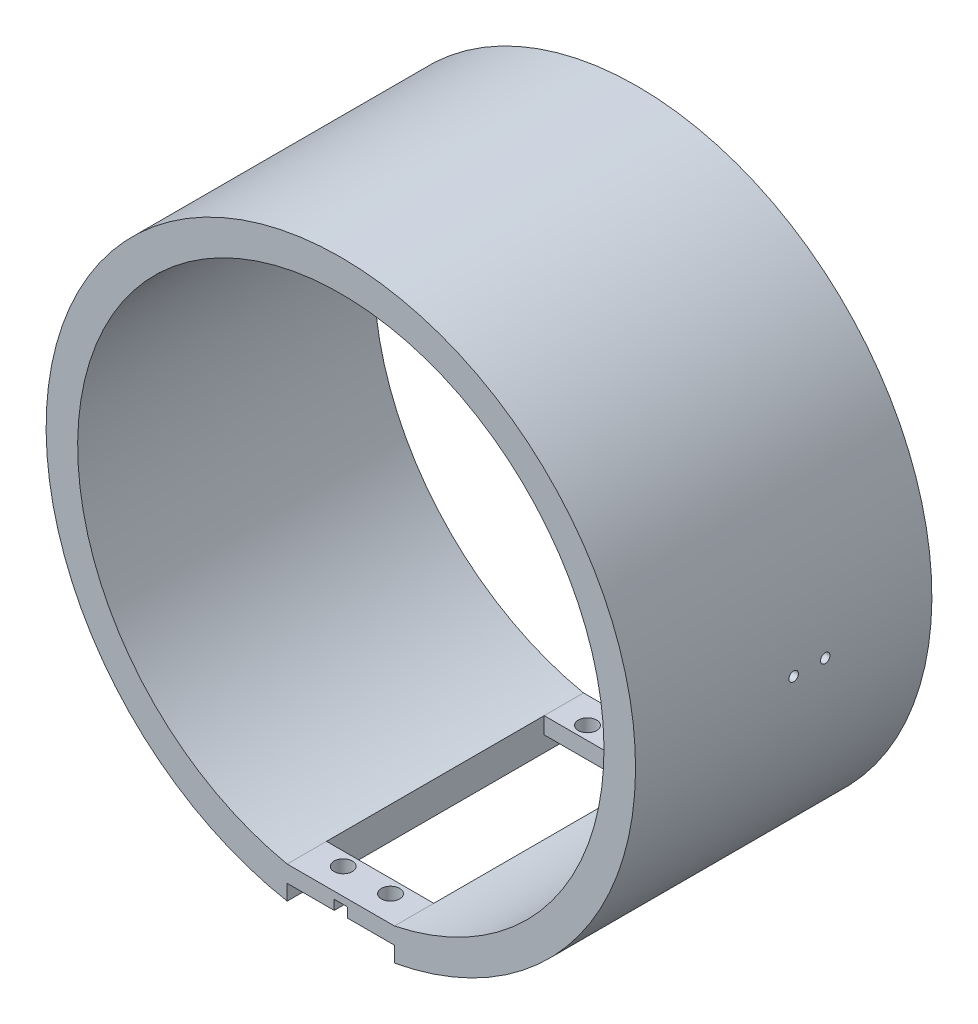
from build123d import *

# Parameters (mm, degrees)
SKETCH1_R                 = 93.40293561
SKETCH1_R_2               = 83.40293561
BOSS_EXTRUDE1_DEPTH       = 93.92
BOSS_EXTRUDE3_DEPTH       = 93.92
CUT_EXTRUDE1_REACH        = 231.001
SKETCH2_W                 = 34
SKETCH2_H                 = 69
CUT_EXTRUDE2_START        = -6.472936
SKETCH3_W                 = 34
SKETCH3_H                 = 12.46
CUT_EXTRUDE2_DEPTH        = 6.472936
M5_CLEARANCE_HOLE1_D      = 5.8
M5_CLEARANCE_HOLE1_DEPTH  = 170.33393561
M5_CLEARANCE_HOLE1_TIP    = 1.742495795
SKETCH8_W                 = 4.19
SKETCH8_H                 = 3.07
CUT_EXTRUDE3_DEPTH        = 12.46
M6_CLEARANCE_HOLE1_REACH  = 219.335
M6_CLEARANCE_HOLE1_BORE_R = 1.5


with BuildPart() as part:
    # Sketch1 → Boss-Extrude1 (new body)
    with BuildSketch(Plane.XY):
        Circle(SKETCH1_R)
        Circle(SKETCH1_R_2, mode=Mode.SUBTRACT)
    extrude(amount=-BOSS_EXTRUDE1_DEPTH)

    # Sketch7 → Boss-Extrude3 (add)
    with BuildSketch(Plane.XY):
        with BuildLine():
            Line((-17, -81.652003456), (17, -81.652003456))
            ThreePointArc((17, -81.652003456), (0, -83.40293561), (-17, -81.652003456))
        make_face()
    extrude(amount=-BOSS_EXTRUDE3_DEPTH)

    # Sketch2 → Cut-Extrude1 (cut, up to next)
    with BuildSketch(Plane(origin=(0, -93.40293561, 0), x_dir=(-1, 0, 0), z_dir=(0, -1, 0)), mode=Mode.PRIVATE) as cut_extrude1_sk1:
        with Locations((0, 46.96)):
            Rectangle(SKETCH2_W, SKETCH2_H)
    cut_extrude1_tool1 = extrude(cut_extrude1_sk1.sketch, amount=-CUT_EXTRUDE1_REACH, mode=Mode.PRIVATE) & part.part
    add(cut_extrude1_tool1.solids().sort_by_distance((0, -93.402936, -46.96))[0], mode=Mode.SUBTRACT)

    # Sketch3 → Cut-Extrude2 (cut)
    with BuildSketch(Plane(origin=(0, -93.40293561, 0), x_dir=(-1, 0, 0), z_dir=(0, -1, 0)).offset(CUT_EXTRUDE2_START)):
        with Locations((0, 87.69)):
            Rectangle(SKETCH3_W, SKETCH3_H)
        with Locations((0, 6.23)):
            Rectangle(SKETCH3_W, SKETCH3_H)
    extrude(amount=CUT_EXTRUDE2_DEPTH, mode=Mode.SUBTRACT)

    # M5 Clearance Hole1
    with Locations(Plane(origin=(-7.5, -86.93, -8.25), x_dir=(0, 0, -1), z_dir=(0, -1, 0))):
        with Locations((0, 0), (0, 15), (77.42, 0), (77.42, 15)):
            Hole(M5_CLEARANCE_HOLE1_D / 2, depth=M5_CLEARANCE_HOLE1_DEPTH)
            with Locations((0, 0, -(M5_CLEARANCE_HOLE1_DEPTH + M5_CLEARANCE_HOLE1_TIP / 2))):  # 118° drill point
                Cone(0, M5_CLEARANCE_HOLE1_D / 2, M5_CLEARANCE_HOLE1_TIP, mode=Mode.SUBTRACT)

    # Sketch8 → Cut-Extrude3 (cut)
    with BuildSketch(Plane.XY):
        with Locations((0, -85.395)):
            Rectangle(SKETCH8_W, SKETCH8_H)
    extrude(amount=-CUT_EXTRUDE3_DEPTH, mode=Mode.SUBTRACT)

    # M6 Clearance Hole1 bore (on position points) → M6 Clearance Hole1 (cut, up to next)
    with BuildSketch(Plane(origin=(93.40293561, 0, -60.116902822), x_dir=(0, 0, 1), z_dir=(1, 0, 0)), mode=Mode.PRIVATE) as m6_clearance_hole1_sk1:
        Circle(M6_CLEARANCE_HOLE1_BORE_R)
    m6_clearance_hole1_tool1 = extrude(m6_clearance_hole1_sk1.sketch, amount=-M6_CLEARANCE_HOLE1_REACH, mode=Mode.PRIVATE) & part.part
    # M6 Clearance Hole1 bore (on position points) → M6 Clearance Hole1 (cut, up to next)
    with BuildSketch(Plane(origin=(93.40293561, 0, -60.116902822), x_dir=(0, 0, 1), z_dir=(1, 0, 0)), mode=Mode.PRIVATE) as m6_clearance_hole1_sk2:
        with Locations((10, 0)):
            Circle(M6_CLEARANCE_HOLE1_BORE_R)
    m6_clearance_hole1_tool2 = extrude(m6_clearance_hole1_sk2.sketch, amount=-M6_CLEARANCE_HOLE1_REACH, mode=Mode.PRIVATE) & part.part
    add(m6_clearance_hole1_tool1.solids().sort_by_distance((93.402936, 0, -60.116903))[0], mode=Mode.SUBTRACT)
    add(m6_clearance_hole1_tool2.solids().sort_by_distance((93.402936, 0, -50.116903))[0], mode=Mode.SUBTRACT)


solid = part.part
